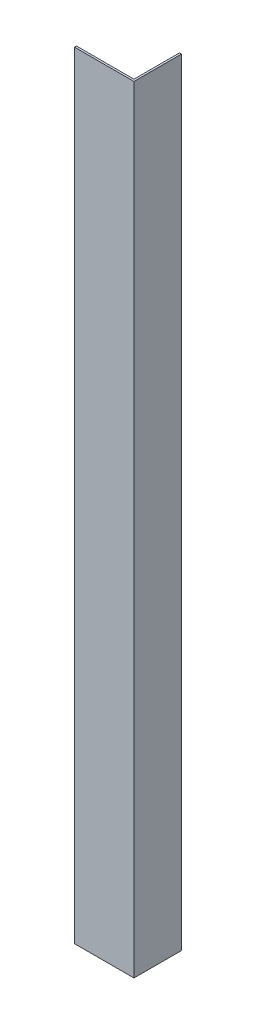
from build123d import *

# Parameters (mm, degrees)
BOSS_EXTRUDE1_DEPTH = 196


with BuildPart() as part:
    # Sketch1 → Boss-Extrude1 (new body)
    with BuildSketch(Plane(origin=(0, 0, 0), x_dir=(1, 0, 0), z_dir=(0, 1, 0))):
        Polygon((0, 0), (15, 0), (15, 12), (14.5, 12), (14.5, 0.5), (0, 0.5), align=None)
    extrude(amount=BOSS_EXTRUDE1_DEPTH)


solid = part.part
